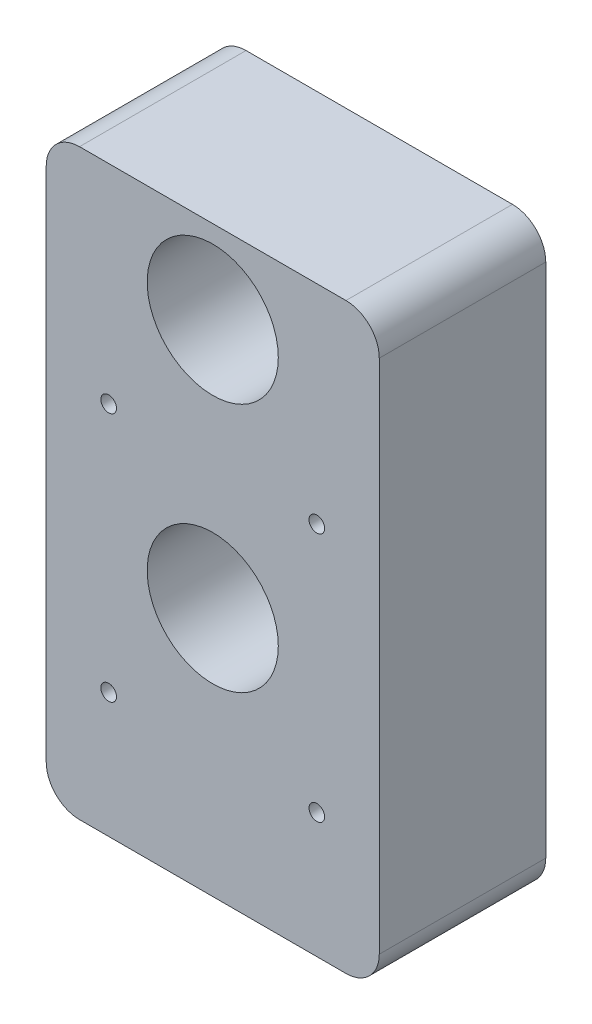
from build123d import *

# Parameters (mm, degrees)
SKETCH1_W           = 25.4
SKETCH1_H           = 44.45
BOSS_EXTRUDE1_DEPTH = 12.7
SKETCH2_R           = 2.75
CUT_EXTRUDE1_DEPTH  = 13.7
SKETCH3_R           = 5
CUT_EXTRUDE2_DEPTH  = 9.525
SKETCH5_R           = 0.5953125
CUT_EXTRUDE3_DEPTH  = 13.7
FILLET1_R           = 2.54


with BuildPart() as part:
    # Sketch1 → Boss-Extrude1 (new body)
    with BuildSketch(Plane.XY):
        with Locations((0, 53.975)):
            Rectangle(SKETCH1_W, SKETCH1_H)
    extrude(amount=BOSS_EXTRUDE1_DEPTH)

    # Sketch2 → Cut-Extrude1 (cut, through all)
    with BuildSketch(Plane.XY.offset(12.7)):
        with Locations((0, 50.8)):
            Circle(SKETCH2_R)
        with Locations((0, 69.85)):
            Circle(SKETCH2_R)
    extrude(amount=-CUT_EXTRUDE1_DEPTH, mode=Mode.SUBTRACT)

    # Sketch3 → Cut-Extrude2 (cut)
    with BuildSketch(Plane.XY.offset(12.7)):
        with Locations((0, 50.8)):
            Circle(SKETCH3_R)
        with Locations((0, 69.85)):
            Circle(SKETCH3_R)
    extrude(amount=-CUT_EXTRUDE2_DEPTH, mode=Mode.SUBTRACT)

    # Sketch5 → Cut-Extrude3 (cut, through all)
    with BuildSketch(Plane.XY.offset(12.7)):
        with Locations((7.9375, 41.275)):
            Circle(SKETCH5_R)
        with Locations((-7.9375, 41.275)):
            Circle(SKETCH5_R)
        with Locations((-7.9375, 60.325)):
            Circle(SKETCH5_R)
        with Locations((7.9375, 60.325)):
            Circle(SKETCH5_R)
    extrude(amount=-CUT_EXTRUDE3_DEPTH, mode=Mode.SUBTRACT)

    # Fillet1
    fillet1_edges = [part.edges().sort_by_distance(p)[0] for p in [
        (-12.7, 76.2, 6.35),
        (12.7, 76.2, 6.35),
        (12.7, 31.75, 6.35),
        (-12.7, 31.75, 6.35),
    ]]
    fillet(fillet1_edges, radius=FILLET1_R)


solid = part.part
